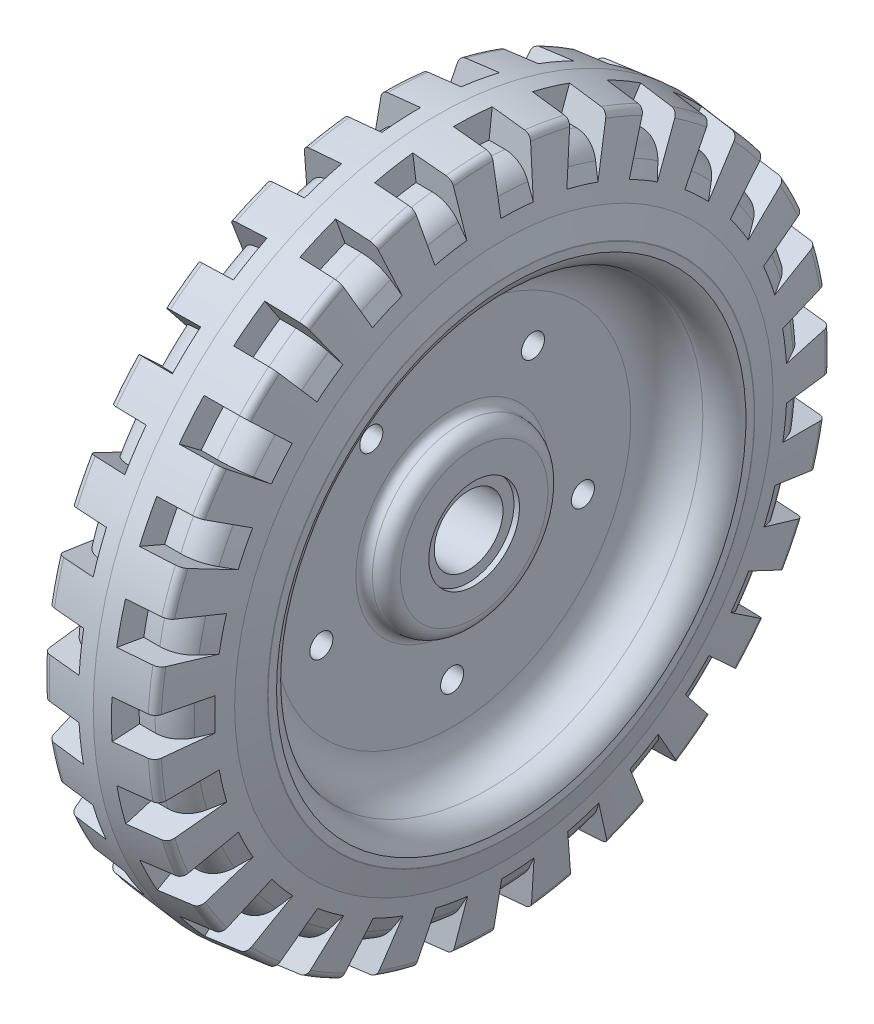
from build123d import *

# Parameters (mm, degrees)
M8_CLEARANCE_HOLE1_D     = 8.4
M8_CLEARANCE_HOLE1_DEPTH = 11
CIRPATTERN1_COUNT        = 5
CUT_REVOLVE1_ANGLE       = 6.5
CIRPATTERN2_COUNT        = 27
CUT_REVOLVE2_ANGLE       = 6.5
CIRPATTERN3_COUNT        = 27
SKETCH8_R                = 16.5
SKETCH8_R_2              = 12.5
CUT_EXTRUDE1_DEPTH       = 2


with BuildPart() as part:
    # Sketch1 → Revolve2 (revolve)
    with BuildSketch(Plane.XY):
        with BuildLine():
            Line((-13.5, 12.5), (13.5, 12.5))
            Line((13.5, 12.5), (13.5, 25))
            Line((13.5, 25), (13.5, 26.840625))
            ThreePointArc((13.5, 26.840625), (11.988854049, 30.488854049), (8.340625, 32))
            Line((8.340625, 32), (8.5, 32))
            ThreePointArc((8.5, 32), (6.378679656, 32.878679656), (5.5, 35))
            Line((5.5, 35), (5.5, 65))
            ThreePointArc((5.5, 65), (9.15737221, 74.254692337), (18.153340487, 78.508896902))
            ThreePointArc((18.153340487, 78.508896902), (23.615611077, 80.575559374), (26.992, 85.340797208))
            Line((26.992, 85.340797208), (26.992, 88.368354727))
            ThreePointArc((26.992, 88.368354727), (26.984200393, 88.47935492), (26.960954853, 88.588173676))
            Line((26.960954853, 88.588173676), (24.287106818, 97.865612596))
            Line((24.287106818, 97.865612596), (20.354975523, 120.795594646))
            ThreePointArc((20.354975523, 120.795594646), (19.517884258, 122.351859714), (17.911624828, 123.088482679))
            Line((17.911624828, 123.088482679), (0, 125))
            Line((0, 125), (-17.911624828, 123.088482679))
            ThreePointArc((-17.911624828, 123.088482679), (-19.517884258, 122.351859714), (-20.354975523, 120.795594646))
            Line((-20.354975523, 120.795594646), (-24.287106818, 97.865612596))
            Line((-24.287106818, 97.865612596), (-26.960954853, 88.588173676))
            ThreePointArc((-26.960954853, 88.588173676), (-26.984200393, 88.47935492), (-26.992, 88.368354727))
            Line((-26.992, 88.368354727), (-26.992, 85.340797208))
            ThreePointArc((-26.992, 85.340797208), (-23.615611077, 80.575559374), (-18.153340487, 78.508896902))
            ThreePointArc((-18.153340487, 78.508896902), (-9.15737221, 74.254692337), (-5.5, 65))
            Line((-5.5, 65), (-5.5, 35))
            ThreePointArc((-5.5, 35), (-6.378679656, 32.878679656), (-8.5, 32))
            Line((-8.5, 32), (-8.340625, 32))
            ThreePointArc((-8.340625, 32), (-11.988854049, 30.488854049), (-13.5, 26.840625))
            Line((-13.5, 26.840625), (-13.5, 25))
            Line((-13.5, 25), (-13.5, 12.5))
        make_face()
    revolve(axis=Axis((-13.5, 0, 0), (1, 0, 0)))

    # M8 Clearance Hole1
    with Locations(Plane(origin=(5.5, -50, 0), x_dir=(0, 0, 1), z_dir=(1, 0, 0))):
        with Locations((0, 0)):
            m8_clearance_hole1 = Hole(M8_CLEARANCE_HOLE1_D / 2, depth=M8_CLEARANCE_HOLE1_DEPTH)

    # CirPattern1: M8 Clearance Hole1 ×5 about axis
    cirpattern1_axis = Axis((0, 0, 0), (1, 0, 0))
    for i in range(1, CIRPATTERN1_COUNT):
        add(m8_clearance_hole1.rotate(cirpattern1_axis, i * 360 / CIRPATTERN1_COUNT), mode=Mode.SUBTRACT)

    # Sketch7 → Cut-Revolve1 (revolve, cut)
    with BuildSketch(Plane.XY):
        with BuildLine():
            Line((20.703996435, 108.939354068), (23.228454943, 104.039075959))
            Line((23.228454943, 104.039075959), (20.354975523, 120.795594646))
            ThreePointArc((20.354975523, 120.795594646), (19.517884258, 122.351859714), (17.911624828, 123.088482679))
            Line((17.911624828, 123.088482679), (6, 124.359683779))
            Line((6, 124.359683779), (6, 114.359683779))
            Line((6, 114.359683779), (11.814304649, 114.359683779))
            ThreePointArc((11.814304649, 114.359683779), (17.02022902, 112.89773692), (20.703996435, 108.939354068))
        make_face()
    cut_revolve1 = revolve(axis=Axis((13.5, 0, 0), (-1, 0, 0)), revolution_arc=CUT_REVOLVE1_ANGLE, mode=Mode.SUBTRACT)

    # CirPattern2: Cut-Revolve1 ×27 about axis
    cirpattern2_axis = Axis((0, 0, 0), (1, 0, 0))
    for i in range(1, CIRPATTERN2_COUNT):
        add(cut_revolve1.rotate(cirpattern2_axis, i * 360 / CIRPATTERN2_COUNT), mode=Mode.SUBTRACT)

    # Sketch7_5 → Cut-Revolve2 (revolve, cut)
    with BuildSketch(Plane.XY):
        with BuildLine():
            Line((-20.354975523, 120.795594646), (-23.228454943, 104.039075959))
            Line((-23.228454943, 104.039075959), (-20.703996435, 108.939354068))
            ThreePointArc((-20.703996435, 108.939354068), (-17.02022902, 112.89773692), (-11.814304649, 114.359683779))
            Line((-11.814304649, 114.359683779), (-6, 114.359683779))
            Line((-6, 114.359683779), (-6, 124.359683779))
            Line((-6, 124.359683779), (-17.911624828, 123.088482679))
            ThreePointArc((-17.911624828, 123.088482679), (-19.517884258, 122.351859714), (-20.354975523, 120.795594646))
        make_face()
    cut_revolve2 = revolve(axis=Axis((13.5, 0, 0), (1, 0, 0)), revolution_arc=CUT_REVOLVE2_ANGLE, mode=Mode.SUBTRACT)

    # CirPattern3: Cut-Revolve2 ×27 about axis
    cirpattern3_axis = Axis((0, 0, 0), (1, 0, 0))
    for i in range(1, CIRPATTERN3_COUNT):
        add(cut_revolve2.rotate(cirpattern3_axis, i * 360 / CIRPATTERN3_COUNT), mode=Mode.SUBTRACT)

    # Sketch8 → Cut-Extrude1 (cut)
    with BuildSketch(Plane(origin=(13.5, 0, 0), x_dir=(0, 0, -1), z_dir=(1, 0, 0))):
        Circle(SKETCH8_R)
        Circle(SKETCH8_R_2, mode=Mode.SUBTRACT)
    cut_extrude1 = extrude(amount=-CUT_EXTRUDE1_DEPTH, mode=Mode.SUBTRACT)

    # Mirror1: Cut-Extrude1 across plane
    add(cut_extrude1.mirror(Plane(origin=(0, 0, 0), x_dir=(0, 0, 1), z_dir=(1, 0, 0))), mode=Mode.SUBTRACT)


solid = part.part
